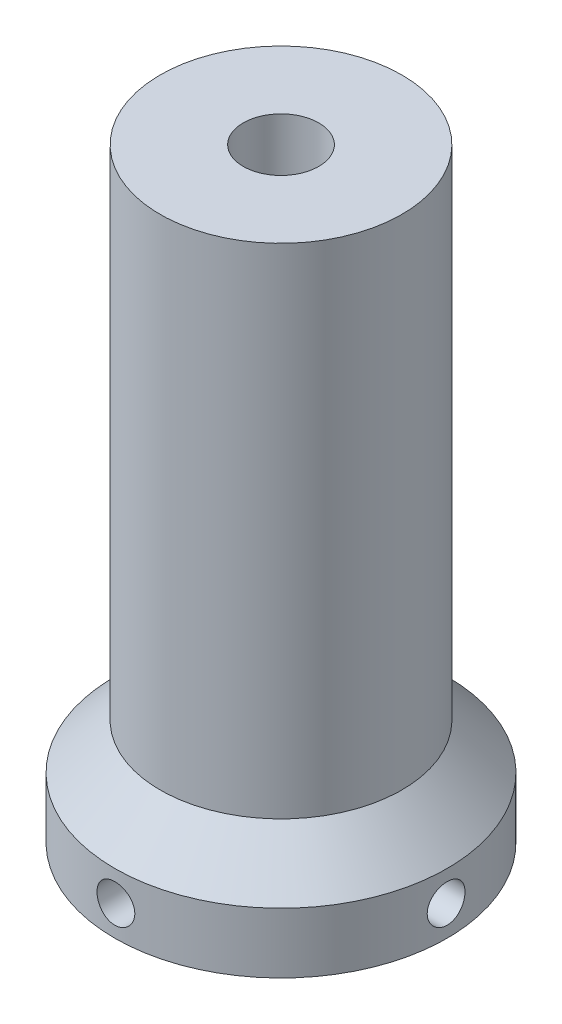
from build123d import *

# Parameters (mm, degrees)
SKETCH13_W        = 1.25
SKETCH13_H        = 11
CIRPATTERN1_COUNT = 4


with BuildPart() as part:
    # Sketch11 → Revolve1 (revolve)
    with BuildSketch(Plane.XY):
        Polygon((8, 40), (2.5, 40), (2.5, 0), (11, 0), (11, 4), (8, 7), (8, 35), align=None)
    revolve(axis=Axis((0, 0, 0), (0, 1, 0)))

    # Sketch13 → M3x0.5 Tapped Hole1 (revolve, cut)
    with BuildSketch(Plane(origin=(0, 2, 0), x_dir=(0, 0, -1), z_dir=(0, 1, 0))):
        with Locations((0.625, 5.5)):
            Rectangle(SKETCH13_W, SKETCH13_H)
    m3x0_5_tapped_hole1 = revolve(axis=Axis((6.35, 2, 0), (-1, 0, 0)), mode=Mode.SUBTRACT)

    # CirPattern1: M3x0.5 Tapped Hole1 ×4 about axis
    cirpattern1_axis = Axis((0, 0, 0), (0, -1, 0))
    for i in range(1, CIRPATTERN1_COUNT):
        add(m3x0_5_tapped_hole1.rotate(cirpattern1_axis, i * 360 / CIRPATTERN1_COUNT), mode=Mode.SUBTRACT)


solid = part.part
